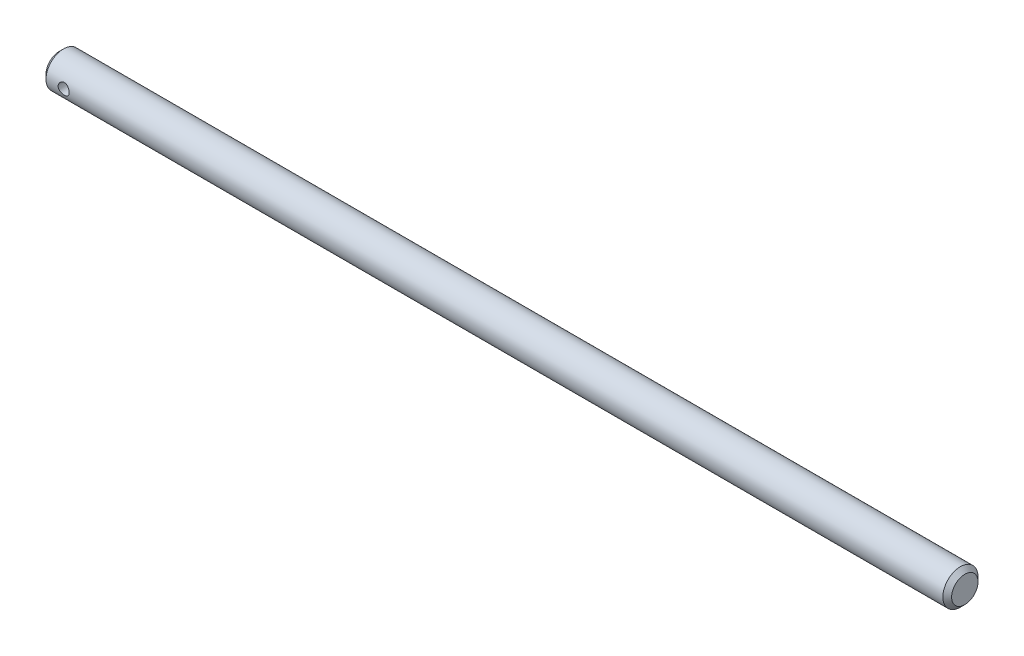
from build123d import *

# Parameters (mm, degrees)
SKETCH1_R               = 6.35
BOSS_EXTRUDE1_DEPTH     = 163.5125
CHAMFER1_SIZE           = 1.5875
SKETCH2_R               = 1.984375
CUT_EXTRUDE1_DEPTH      = 7.35
CUT_EXTRUDE1_DEPTH_BACK = 7.35


with BuildPart() as part:
    # Sketch1 → Boss-Extrude1 (new body, symmetric)
    with BuildSketch(Plane(origin=(0, 0, 0), x_dir=(0, 0, -1), z_dir=(1, 0, 0))):
        Circle(SKETCH1_R)
    extrude(amount=BOSS_EXTRUDE1_DEPTH, both=True)

    # Chamfer1
    chamfer1_edges = [part.edges().sort_by_distance(p)[0] for p in [
        (-163.5125, 0, 6.35),
        (163.5125, 0, 6.35),
    ]]
    chamfer(chamfer1_edges, length=CHAMFER1_SIZE)

    # Sketch2 → Cut-Extrude1 (cut, two sides)
    with BuildSketch(Plane.XY) as cut_extrude1_sk:
        with Locations((-155.575, 0)):
            Circle(SKETCH2_R)
    extrude(amount=CUT_EXTRUDE1_DEPTH, mode=Mode.SUBTRACT)
    extrude(cut_extrude1_sk.sketch, amount=-CUT_EXTRUDE1_DEPTH_BACK, mode=Mode.SUBTRACT)


solid = part.part
